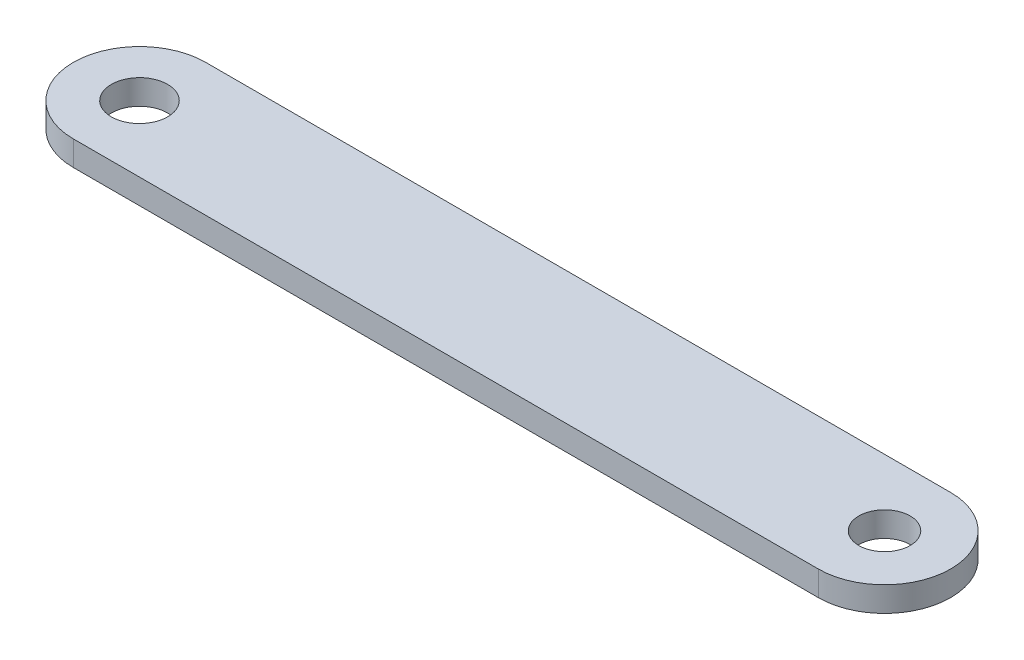
from build123d import *

# Parameters (mm, degrees)
BOSS_EXTRUDE1_DEPTH  = 1.5
M3_CLEARANCE_HOLE1_D = 3.4
SKETCH4_R            = 1.55
CUT_EXTRUDE1_DEPTH   = 2.5


with BuildPart() as part:
    # Sketch1 → Boss-Extrude1 (new body)
    with BuildSketch(Plane(origin=(0, 0, 0), x_dir=(1, 0, 0), z_dir=(0, 1, 0))):
        with BuildLine():
            Line((0, 4), (45, 4))
            ThreePointArc((45, 4), (49, 0), (45, -4))
            Line((45, -4), (0, -4))
            ThreePointArc((0, -4), (-4, 0), (0, 4))
        make_face()
    extrude(amount=BOSS_EXTRUDE1_DEPTH)

    # M3 Clearance Hole1 (through all)
    with Locations(Plane(origin=(0, 1.5, 0), x_dir=(1, 0, 0), z_dir=(0, 1, 0))):
        with Locations((0, 0)):
            Hole(M3_CLEARANCE_HOLE1_D / 2)

    # Sketch4 → Cut-Extrude1 (cut, through all)
    with BuildSketch(Plane(origin=(0, 1.5, 0), x_dir=(1, 0, 0), z_dir=(0, 1, 0))):
        with Locations((45, 0)):
            Circle(SKETCH4_R)
    extrude(amount=-CUT_EXTRUDE1_DEPTH, mode=Mode.SUBTRACT)


solid = part.part
